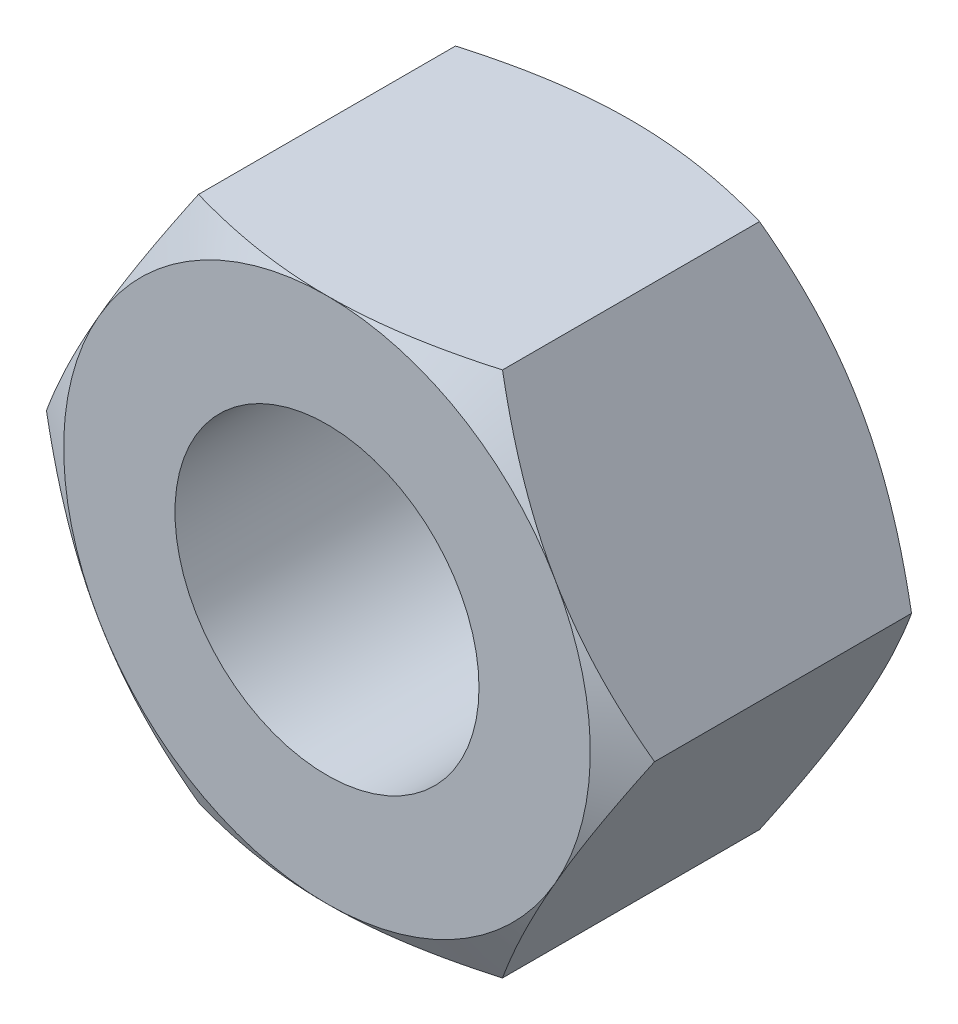
from build123d import *

# Parameters (mm, degrees)
SKETCH4_R           = 4.5
BOSS_EXTRUDE1_DEPTH = 4.5
SKETCH5_OUTSIDE_W   = 56.268
SKETCH5_OUTSIDE_H   = 53.856
SKETCH5_OUTSIDE_R   = 7.794228634
CUT_EXTRUDE1_DEPTH  = 9
CUT_EXTRUDE1_TAPER  = 60


with BuildPart() as part:
    # Sketch4 → Boss-Extrude1 (new body, symmetric)
    with BuildSketch(Plane.XY):
        Polygon((4.5, 7.794228634), (-4.5, 7.794228634), (-9, 0), (-4.5, -7.794228634), (4.5, -7.794228634), (9, 0), align=None)
        Circle(SKETCH4_R, mode=Mode.SUBTRACT)
    extrude(amount=BOSS_EXTRUDE1_DEPTH, both=True)

    # Sketch5 outside → Cut-Extrude1 (cut)
    with BuildSketch(Plane.XY.offset(4.5)):
        Rectangle(SKETCH5_OUTSIDE_W, SKETCH5_OUTSIDE_H)
        Circle(SKETCH5_OUTSIDE_R, mode=Mode.SUBTRACT)
    cut_extrude1 = extrude(amount=-CUT_EXTRUDE1_DEPTH, taper=CUT_EXTRUDE1_TAPER, mode=Mode.SUBTRACT)

    # Mirror1: Cut-Extrude1 across plane
    add(cut_extrude1.mirror(Plane.XY), mode=Mode.SUBTRACT)


solid = part.part
